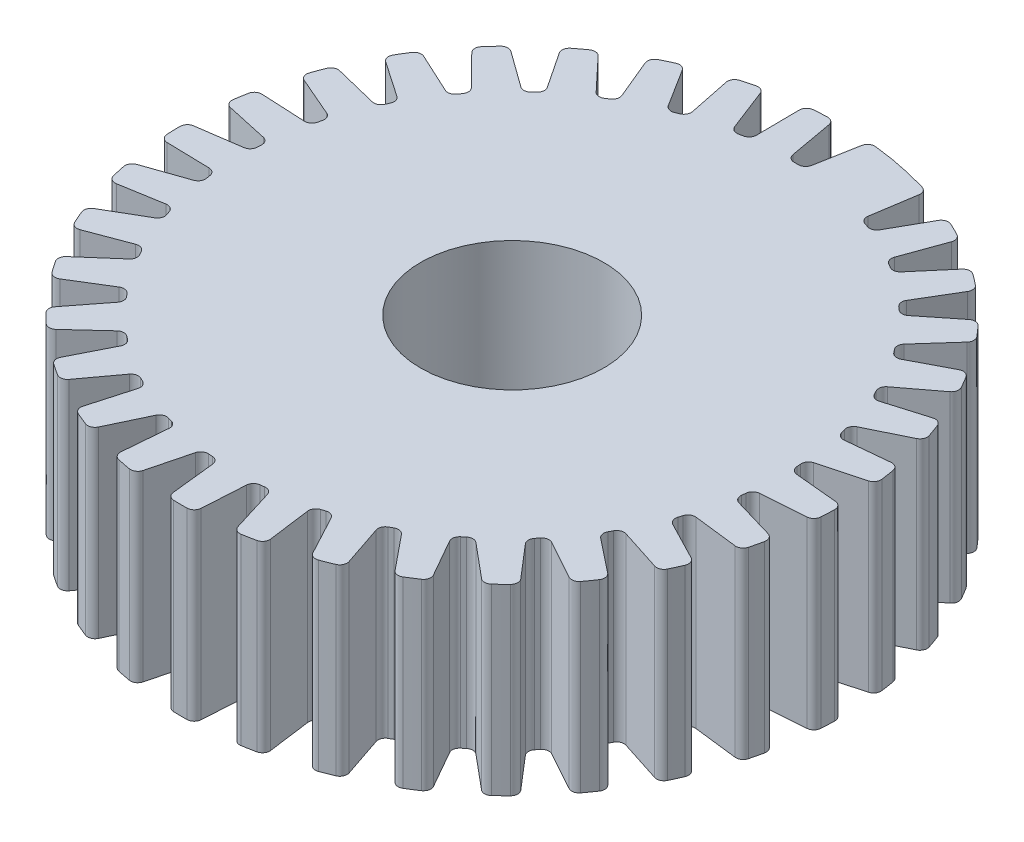
from build123d import *

# Parameters (mm, degrees)
SKETCH1_R                = 18
BOSS_EXTRUDE1_DEPTH      = 10
CUT_EXTRUDE1_DEPTH       = 11
FILLET1_R                = 0.4
CIRPATTERN1_COUNT        = 32
CIRPATTERN1_ANGLE        = 341
FILLET1_OF_CIRPATTERN1_R = 0.4
SKETCH3_R                = 5
CUT_EXTRUDE4_DEPTH       = 10


with BuildPart() as part:
    # Sketch1 → Boss-Extrude1 (new body)
    with BuildSketch(Plane(origin=(0, 0, 0), x_dir=(1, 0, 0), z_dir=(0, 1, 0))):
        with Locations((-0.580095251, 0.370962199)):
            Circle(SKETCH1_R)
    extrude(amount=BOSS_EXTRUDE1_DEPTH)

    # Sketch2 → Cut-Extrude1 (cut, through all)
    with BuildSketch(Plane(origin=(0, 10, 0), x_dir=(1, 0, 0), z_dir=(0, 1, 0))):
        Polygon((-1.000000119, 18.366063752), (-0.450000119, 15.301475281), (0.449999881, 15.301475281), (0.999999881, 18.301475281), (0.999999881, 19.649627729), (-1.000000119, 19.649627729), align=None)
    cut_extrude1 = extrude(amount=-CUT_EXTRUDE1_DEPTH, mode=Mode.SUBTRACT)

    # Fillet1
    fillet1_edges = [part.edges().sort_by_distance(p)[0] for p in [
        (-1.000000119, 5, -18.366063752),
        (0.999999881, 5, -18.301475281),
        (0.449999881, 5, -15.301475281),
        (-0.450000119, 5, -15.301475281),
    ]]
    fillet(fillet1_edges, radius=FILLET1_R)

    # CirPattern1: Cut-Extrude1 ×32 about axis
    cirpattern1_axis = Axis((-0.580095251, 0, -0.370962199), (0, 1, 0))
    for i in range(1, CIRPATTERN1_COUNT):
        add(cut_extrude1.rotate(cirpattern1_axis, i * CIRPATTERN1_ANGLE / (CIRPATTERN1_COUNT - 1)), mode=Mode.SUBTRACT)

    # Fillet1 of CirPattern1
    fillet1_of_cirpattern1_edges = [part.edges().sort_by_distance(p)[0] for p in [
        (-4.425912533, 5, -17.955321427),
        (-2.450334105, 5, -18.273537618),
        (-2.417802069, 5, -15.22371112),
        (-3.301266535, 5, -15.051983025),
        (-7.710507956, 5, -16.898430688),
        (-5.83194498, 5, -17.587758488),
        (-5.218076319, 5, -14.600173297),
        (-6.052541789, 5, -14.263027363),
        (-10.73309185, 5, -15.234227657),
        (-9.020573311, 5, -16.269337277),
        (-7.847925019, 5, -13.453774104),
        (-8.60272853, 5, -12.963598973),
        (-13.382597456, 5, -13.023864526),
        (-11.899050933, 5, -14.366720209),
        (-10.210712712, 5, -11.826638704),
        (-10.858118532, 5, -11.201446171),
        (-15.561667013, 5, -10.348562489),
        (-14.361606362, 5, -11.949820152),
        (-12.219617269, 5, -9.778557219),
        (-12.735836062, 5, -9.041320379),
        (-17.190229231, 5, -7.306627212),
        (-16.31775144, 5, -9.10744763),
        (-13.800820221, 5, -7.384787699),
        (-14.1668832, 5, -6.562596787),
        (-18.20844156, 5, -4.009836533),
        (-17.695606378, 5, -5.944047418),
        (-14.896219264, 5, -4.73329072),
        (-15.098675213, 5, -3.856357661),
        (-18.578889143, 5, -0.579333114),
        (-18.444541024, 5, -2.575860662),
        (-15.465563266, 5, -1.921497218),
        (-15.496972813, 5, -1.022045473),
        (-18.28795965, 5, 2.858827027),
        (-18.5370353, 5, 0.873346483),
        (-15.487931322, 5, 0.947271676),
        (-15.347140304, 5, 1.836191182),
        (-17.346343468, 5, 6.178306519),
        (-17.969690445, 5, 4.276830719),
        (-14.962501503, 5, 3.76760123),
        (-14.654683374, 5, 4.613324589),
        (-15.788640881, 5, 9.257128984),
        (-16.763353905, 5, 7.509528861),
        (-13.908581062, 5, 6.435856652),
        (-13.445046794, 5, 7.207307222),
        (-13.672090656, 5, 11.982161144),
        (-14.96235328, 5, 10.45265337),
        (-12.36489697, 5, 8.853991205),
        (-11.762679424, 5, 9.522821548),
        (-11.074466771, 5, 14.253269966),
        (-12.632867479, 5, 12.998057272),
        (-10.388172879, 5, 10.933149005),
        (-9.66940092, 5, 11.474782526),
        (-8.091220561, 5, 15.987002117),
        (-9.860494931, 5, 15.05220809),
        (-8.051044765, 5, 12.596930082),
        (-7.242130123, 5, 12.991464114),
        (-4.831973295, 5, 17.119650514),
        (-6.747108222, 5, 16.539624752),
        (-5.439391882, 5, 13.784197748),
        (-4.570058638, 5, 14.017134888),
        (-1.41648808, 5, 17.609595274),
        (-3.407110716, 5, 17.405651189),
        (-2.649181067, 5, 14.451325099),
        (-1.751373422, 5, 14.514105925),
        (2.02973092, 5, 17.438833065),
        (0.036767262, 5, 17.618464713),
        (0.217059615, 5, 14.573798119),
        (1.110351152, 5, 14.46411571),
        (5.380050205, 5, 16.613638654),
        (3.457978237, 5, 17.170245356),
        (3.054008338, 5, 14.14711646),
        (3.909959202, 5, 13.869001165),
        (8.511360171, 5, 15.164334331),
        (6.730807645, 5, 16.077463222),
        (5.757419623, 5, 13.18695881),
        (6.544577359, 5, 12.750630151),
        (11.308598853, 5, 13.144175702),
        (9.734993297, 5, 14.380273282),
        (8.227954912, 5, 11.728606768),
        (8.917394911, 5, 11.150097919),
        (13.668979942, 5, 10.627394775),
        (12.36014449, 5, 12.141039856),
        (10.374832821, 5, 9.825648404),
        (10.941221173, 5, 9.126217038),
        (15.505769743, 5, 7.706472257),
        (14.509798382, 5, 9.442044992),
        (12.119164963, 5, 7.548009128),
        (12.541689369, 5, 6.753356294),
        (16.75147425, 5, 4.488739296),
        (16.104964578, 5, 6.382464967),
        (13.396854748, 5, 4.979382237),
        (13.659989282, 5, 4.118707956),
        (17.360319263, 5, 1.092433527),
        (17.087027688, 5, 3.074725985),
        (14.160952656, 5, 2.214153552),
        (14.255028273, 5, 1.319083846),
        (17.309932387, 5, -2.357645644),
        (17.41990118, 5, -0.359626992),
        (14.383381427, 5, -0.646066847),
        (14.304941258, 5, -1.542642076),
        (16.602165119, 5, -5.734722874),
        (17.091353407, 5, -3.794396487),
        (14.055967773, 5, -3.496178352),
        (13.807894153, 5, -4.361313879),
        (15.263024815, 5, -8.914705323),
        (16.113457065, 5, -7.103369722),
        (13.190742718, 5, -6.231451811),
        (12.782151268, 5, -7.033357683),
        (13.341719034, 5, -11.780742521),
        (14.522145575, 5, -10.164956381),
        (11.819499503, 5, -8.751377869),
        (11.265404175, 5, -9.460587547),
        (10.908847374, 5, -14.227520118),
        (12.375892684, 5, -12.866656522),
        (9.992625328, 5, -10.963360247),
        (9.313386706, 5, -11.553813374),
        (8.053807243, 5, -16.165129722),
        (9.753563815, 5, -15.109194465),
        (7.777249842, 5, -12.786118253),
        (6.997826979, 5, -13.236118253),
        (4.881508898, 5, -17.52237264),
        (6.7515181, 5, -16.810166732),
        (5.25477842, 5, -14.15267349),
        (4.403811702, 5, -14.445684829),
    ]]
    fillet(fillet1_of_cirpattern1_edges, radius=FILLET1_OF_CIRPATTERN1_R)

    # Sketch3 → Cut-Extrude4 (cut)
    with BuildSketch(Plane(origin=(0, 0, 0), x_dir=(1, 0, 0), z_dir=(0, 1, 0))):
        with Locations((-0.580095251, 0.370962199)):
            Circle(SKETCH3_R)
    extrude(amount=CUT_EXTRUDE4_DEPTH, mode=Mode.SUBTRACT)


solid = part.part
